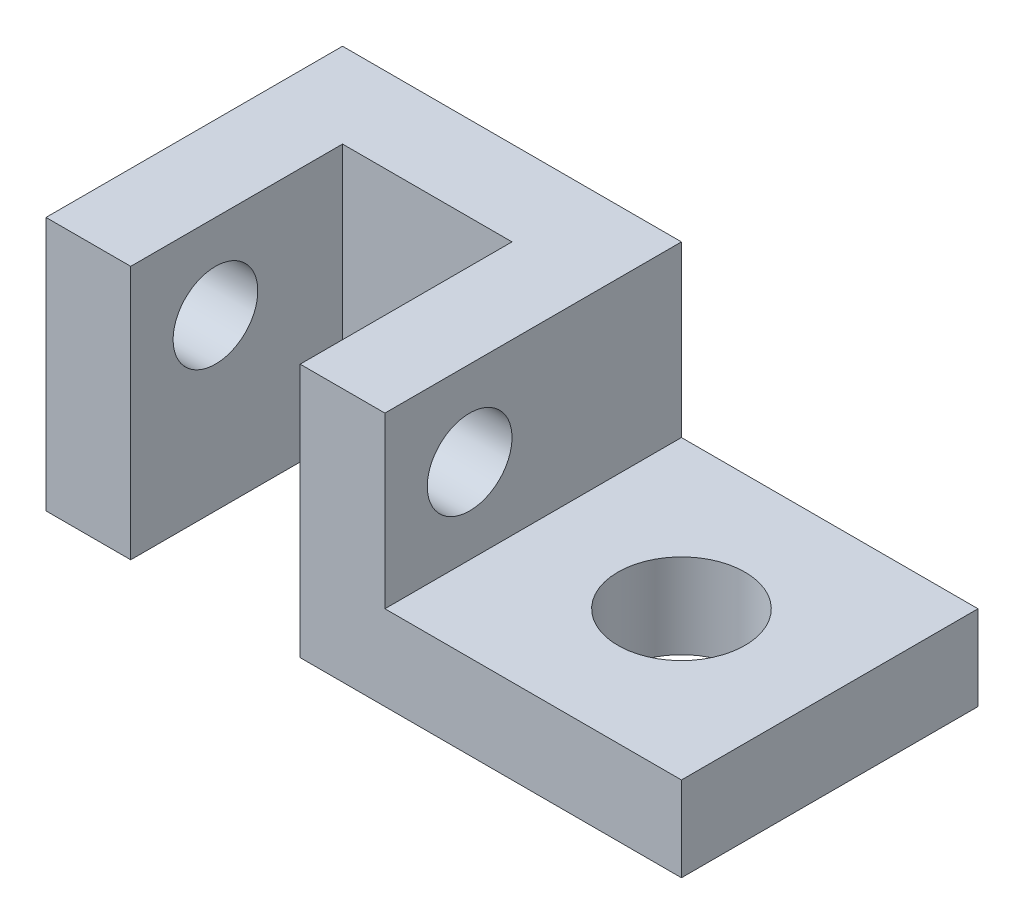
from build123d import *

# Parameters (mm, degrees)
SKETCH1_W           = 75
SKETCH1_H           = 35
BOSS_EXTRUDE1_DEPTH = 30
SKETCH2_W           = 20
SKETCH2_H           = 30
CUT_EXTRUDE1_DEPTH  = 25
SKETCH3_W           = 35
SKETCH3_H           = 20
CUT_EXTRUDE2_DEPTH  = 36
SKETCH4_R           = 7.5
CUT_EXTRUDE3_DEPTH  = 11
SKETCH5_R           = 5
CUT_EXTRUDE4_DEPTH  = 76


with BuildPart() as part:
    # Sketch1 → Boss-Extrude1 (new body)
    with BuildSketch(Plane(origin=(0, 0, 0), x_dir=(1, 0, 0), z_dir=(0, 1, 0))):
        with Locations((37.5, 17.5)):
            Rectangle(SKETCH1_W, SKETCH1_H)
    extrude(amount=BOSS_EXTRUDE1_DEPTH)

    # Sketch2 → Cut-Extrude1 (cut)
    with BuildSketch(Plane.XY):
        with Locations((20, 15)):
            Rectangle(SKETCH2_W, SKETCH2_H)
    extrude(amount=-CUT_EXTRUDE1_DEPTH, mode=Mode.SUBTRACT)

    # Sketch3 → Cut-Extrude2 (cut, through all)
    with BuildSketch(Plane.XY):
        with Locations((57.5, 20)):
            Rectangle(SKETCH3_W, SKETCH3_H)
    extrude(amount=-CUT_EXTRUDE2_DEPTH, mode=Mode.SUBTRACT)

    # Sketch4 → Cut-Extrude3 (cut, through all)
    with BuildSketch(Plane(origin=(0, 10, 0), x_dir=(1, 0, 0), z_dir=(0, 1, 0))):
        with Locations((57.5, 17.5)):
            Circle(SKETCH4_R)
    extrude(amount=-CUT_EXTRUDE3_DEPTH, mode=Mode.SUBTRACT)

    # Sketch5 → Cut-Extrude4 (cut, through all)
    with BuildSketch(Plane.ZY):
        with Locations((-10, 20)):
            Circle(SKETCH5_R)
    extrude(amount=-CUT_EXTRUDE4_DEPTH, mode=Mode.SUBTRACT)


solid = part.part
